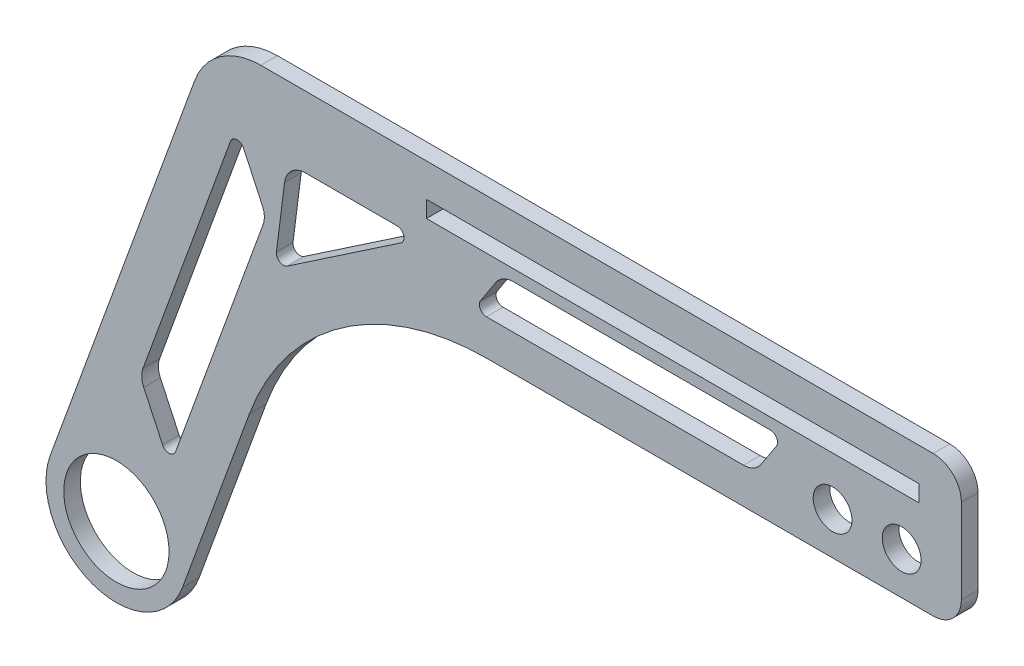
from build123d import *

# Parameters (mm, degrees)
SKETCH1_R           = 9.5025
SKETCH1_W           = 88.9
SKETCH1_H           = 3
BOSS_EXTRUDE1_DEPTH = 3
CUT_EXTRUDE1_DEPTH  = 4
CUT_EXTRUDE2_DEPTH  = 127
FILLET1_R           = 3.81
FILLET2_R           = 1.27
FILLET3_R           = 5.08
SKETCH4_R           = 3.5025
CUT_EXTRUDE3_DEPTH  = 16.002


with BuildPart() as part:
    # Sketch1 → Boss-Extrude1 (new body)
    with BuildSketch(Plane.XY):
        with BuildLine():
            Line((-11.934096284, 4.34365582), (14.127838637, 75.948233524))
            ThreePointArc((14.127838637, 75.948233524), (18.77751418, 82.007808666), (26.061934921, 84.304577704))
            Line((26.061934921, 84.304577704), (152.474181009, 84.304577704))
            Line((152.474181009, 84.304577704), (152.474181009, 58.904577704))
            Line((152.474181009, 58.904577704), (66.968059304, 58.904577704))
            ThreePointArc((66.968059304, 58.904577704), (40.744144634, 50.636209169), (24.005312681, 28.821738657))
            Line((24.005312681, 28.821738657), (11.934096284, -4.34365582))
            ThreePointArc((11.934096284, -4.34365582), (-4.34365582, -11.934096284), (-11.934096284, 4.34365582))
        make_face()
        Circle(SKETCH1_R, mode=Mode.SUBTRACT)
        with Locations((100.404181009, 76.804577704)):
            Rectangle(SKETCH1_W, SKETCH1_H, mode=Mode.SUBTRACT)
    extrude(amount=BOSS_EXTRUDE1_DEPTH)

    # Sketch2 → Cut-Extrude1 (cut, through all)
    with BuildSketch(Plane.XY.offset(3)):
        Polygon((27.008098555, 61.075884743), (9.633475274, 13.339499607), (4.26622335, 24.849608502), (21.640846631, 72.585993638), align=None)
    extrude(amount=-CUT_EXTRUDE1_DEPTH, mode=Mode.SUBTRACT)

    # Sketch3 → Cut-Extrude2 (cut)
    with BuildSketch(Plane.XY.offset(3)):
        Polygon((30.777663682, 71.512392484), (28.523924397, 53.747624001), (54.773358423, 71.512392484), align=None)
        Polygon((64.436448885, 65.362999195), (69.566826389, 73.272331181), (120.366826389, 73.272331181), (115.236448885, 65.362999195), align=None)
    extrude(amount=-CUT_EXTRUDE2_DEPTH, mode=Mode.SUBTRACT)

    # Fillet1
    fillet1_edges = [part.edges().sort_by_distance(p)[0] for p in [
        (27.008098555, 61.075884743, 1.5),
        (4.26622335, 24.849608502, 1.5),
        (30.777663682, 71.512392484, 1.5),
        (115.236448885, 65.362999195, 1.5),
        (69.566826389, 73.272331181, 1.5),
    ]]
    fillet(fillet1_edges, radius=FILLET1_R)

    # Fillet2
    fillet2_edges = [part.edges().sort_by_distance(p)[0] for p in [
        (9.633475274, 13.339499607, 1.5),
        (21.640846631, 72.585993638, 1.5),
        (54.773358423, 71.512392484, 1.5),
        (28.523924397, 53.747624001, 1.5),
        (64.436448885, 65.362999195, 1.5),
        (120.366826389, 73.272331181, 1.5),
    ]]
    fillet(fillet2_edges, radius=FILLET2_R)

    # Fillet3
    fillet3_edges = [part.edges().sort_by_distance(p)[0] for p in [
        (152.474181009, 84.304577704, 1.5),
        (152.474181009, 58.904577704, 1.5),
    ]]
    fillet(fillet3_edges, radius=FILLET3_R)

    # Sketch4 → Cut-Extrude3 (cut)
    with BuildSketch(Plane.XY.offset(3)):
        with Locations((141.694177318, 66.514238531)):
            Circle(SKETCH4_R)
        with Locations((129.235425653, 66.514238531)):
            Circle(SKETCH4_R)
    extrude(amount=-CUT_EXTRUDE3_DEPTH, mode=Mode.SUBTRACT)


solid = part.part
